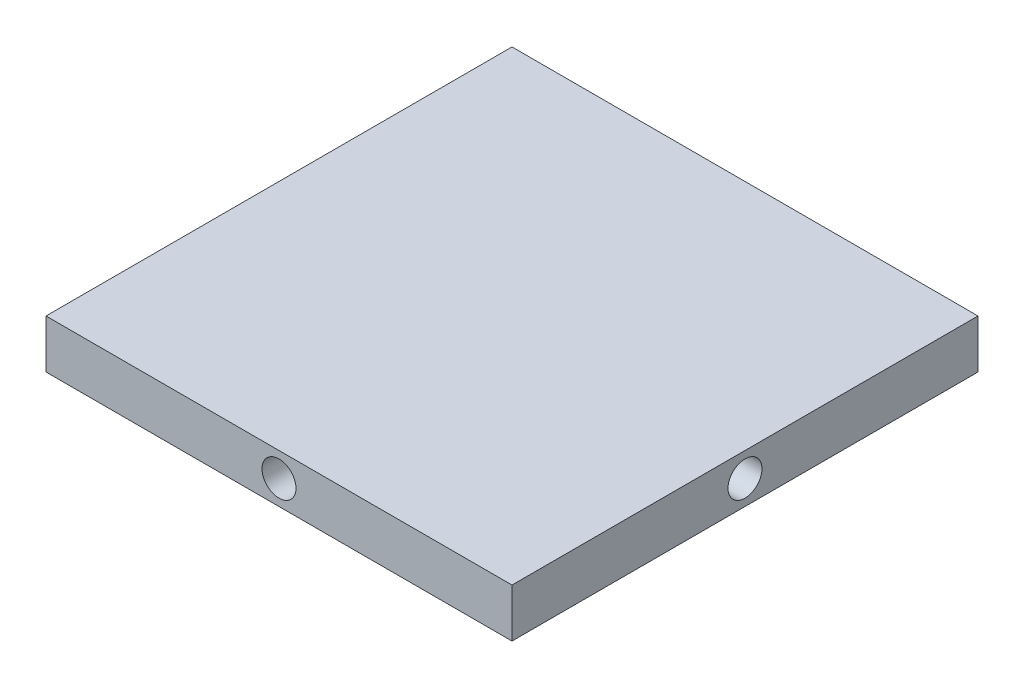
from build123d import *

# Parameters (mm, degrees)
SKETCH_1_W          = 96
SKETCH_1_H          = 96
EXTRUDE_1_DEPTH     = 10
SKETCH_2_R          = 3.5
CUT_EXTRUDE_1_DEPTH = 10
SKETCH_3_R          = 3.5
CUT_EXTRUDE_2_DEPTH = 10
CUT_EXTRUDE_3_DEPTH = 10
SKETCH_5_R          = 3.5
CUT_EXTRUDE_4_DEPTH = 10


with BuildPart() as part:
    # 草图1 → 凸台-拉伸1 (new body)
    with BuildSketch(Plane(origin=(0, 0, 0), x_dir=(1, 0, 0), z_dir=(0, 1, 0))):
        Rectangle(SKETCH_1_W, SKETCH_1_H)
    extrude(amount=EXTRUDE_1_DEPTH)

    # 草图2 → 切除-拉伸1 (cut)
    with BuildSketch(Plane.XY.offset(48)):
        with Locations((0, 5)):
            Circle(SKETCH_2_R)
    extrude(amount=-CUT_EXTRUDE_1_DEPTH, mode=Mode.SUBTRACT)

    # 草图3 → 切除-拉伸2 (cut)
    with BuildSketch(Plane(origin=(48, 0, 0), x_dir=(0, 0, -1), z_dir=(1, 0, 0))):
        with Locations((0, 5)):
            Circle(SKETCH_3_R)
    extrude(amount=-CUT_EXTRUDE_2_DEPTH, mode=Mode.SUBTRACT)

    # 草图4 → 切除-拉伸3 (cut)
    with BuildSketch(Plane(origin=(0, 0, -48), x_dir=(-1, 0, 0), z_dir=(0, 0, -1))):
        with BuildLine():
            ThreePointArc((3.481164431, 5.362621295), (0, 8.5), (-3.481164431, 5.362621295))
            Line((-3.481164431, 5.362621295), (0, 5))
            Line((0, 5), (3.481164431, 5.362621295))
        make_face()
        with BuildLine():
            Line((0, 5), (-3.481164431, 5.362621295))
            ThreePointArc((-3.481164431, 5.362621295), (-3.5, 5), (-3.481164431, 4.637378705))
            Line((-3.481164431, 4.637378705), (0, 5))
        make_face()
        with BuildLine():
            Line((3.481164431, 5.362621295), (0, 5))
            Line((0, 5), (3.481164431, 4.637378705))
            ThreePointArc((3.481164431, 4.637378705), (3.495287936, 4.818444924), (3.5, 5))
            ThreePointArc((3.5, 5), (3.495287936, 5.181555076), (3.481164431, 5.362621295))
        make_face()
        with BuildLine():
            Line((3.481164431, 4.637378705), (0, 5))
            Line((0, 5), (-3.481164431, 4.637378705))
            ThreePointArc((-3.481164431, 4.637378705), (0, 1.5), (3.481164431, 4.637378705))
        make_face()
    extrude(amount=-CUT_EXTRUDE_3_DEPTH, mode=Mode.SUBTRACT)

    # 草图5 → 切除-拉伸4 (cut)
    with BuildSketch(Plane.ZY.offset(48)):
        with Locations((0, 5)):
            Circle(SKETCH_5_R)
    extrude(amount=-CUT_EXTRUDE_4_DEPTH, mode=Mode.SUBTRACT)


solid = part.part
